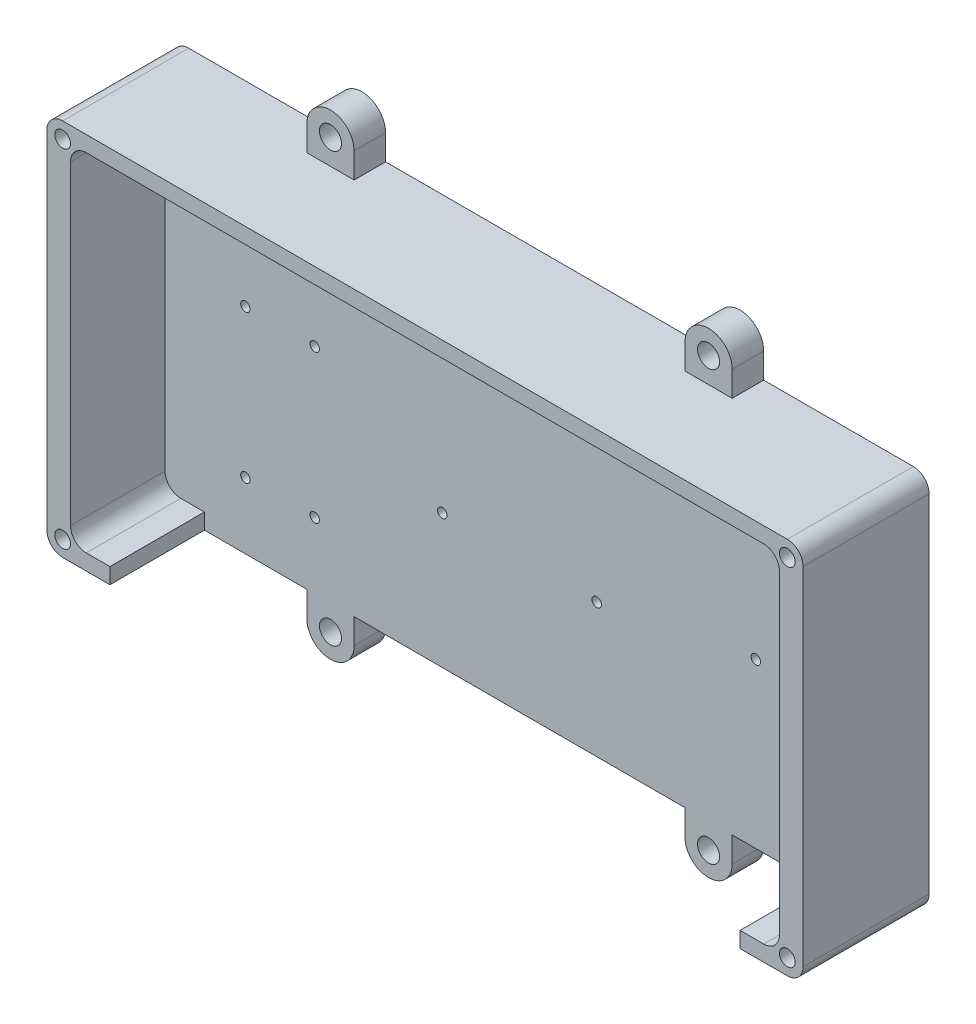
from build123d import *

# Parameters (mm, degrees)
BOSS_EXTRUDE1_DEPTH                 = 10
SKETCH3_R                           = 3.5
IZVRTINA_VIJACENJE_NOSILCA_M7_DEPTH = 10
BOSS_EXTRUDE2_DEPTH                 = 30
SKETCH8_W                           = 200
SKETCH8_H                           = 30
IZVRTINA_KABLI_DEPTH                = 5
SKETCH10_R                          = 1.5
IZVRTINE_RPI_M2_5_HEAT_INSERT_DEPTH = 10
SKETCH11_R                          = 1.5
IZVRTINE_BUCK_M2_HEAT_INSERTS_DEPTH = 10
SKETCH12_R                          = 1.5
IZVRTINE_UNO_M2_5_HEAT_INSERT_DEPTH = 10
SKETCH14_R                          = 2.5
IZVRTINE_TOP_M4_HEAT_INSERT_DEPTH   = 6


with BuildPart() as part:
    # Sketch2 → Boss-Extrude1 (new body)
    with BuildSketch(Plane.XY):
        with BuildLine():
            Line((52.5, 60), (-52.5, 60))
            Line((-52.5, 60), (-52.5, 68))
            ThreePointArc((-52.5, 68), (-60, 75.5), (-67.5, 68))
            Line((-67.5, 68), (-67.5, 60))
            Line((-67.5, 60), (-115, 60))
            ThreePointArc((-115, 60), (-118.535533906, 58.535533906), (-120, 55))
            Line((-120, 55), (-120, -55))
            ThreePointArc((-120, -55), (-118.535533906, -58.535533906), (-115, -60))
            Line((-115, -60), (-67.5, -60))
            Line((-67.5, -60), (-67.5, -68))
            ThreePointArc((-67.5, -68), (-60, -75.5), (-52.5, -68))
            Line((-52.5, -68), (-52.5, -60))
            Line((-52.5, -60), (52.5, -60))
            Line((52.5, -60), (52.5, -68))
            ThreePointArc((52.5, -68), (60, -75.5), (67.5, -68))
            Line((67.5, -68), (67.5, -60))
            Line((67.5, -60), (115, -60))
            ThreePointArc((115, -60), (118.535533906, -58.535533906), (120, -55))
            Line((120, -55), (120, 55))
            ThreePointArc((120, 55), (118.535533906, 58.535533906), (115, 60))
            Line((115, 60), (67.5, 60))
            Line((67.5, 60), (67.5, 68))
            ThreePointArc((67.5, 68), (60, 75.5), (52.5, 68))
            Line((52.5, 68), (52.5, 60))
        make_face()
    extrude(amount=BOSS_EXTRUDE1_DEPTH)

    # Sketch3 → izvrtina_vijacenje_nosilca_m7 (cut)
    with BuildSketch(Plane.XY.offset(10)):
        with Locations((-60, 68)):
            Circle(SKETCH3_R)
        with Locations((-60, -68)):
            Circle(SKETCH3_R)
        with Locations((60, -68)):
            Circle(SKETCH3_R)
        with Locations((60, 68)):
            Circle(SKETCH3_R)
    extrude(amount=-IZVRTINA_VIJACENJE_NOSILCA_M7_DEPTH, mode=Mode.SUBTRACT)

    # Sketch7 → Boss-Extrude2 (add)
    with BuildSketch(Plane.XY.offset(10)):
        with BuildLine():
            Line((-115, -60), (115, -60))
            ThreePointArc((115, -60), (118.535533906, -58.535533906), (120, -55))
            Line((120, -55), (120, 55))
            ThreePointArc((120, 55), (118.535533906, 58.535533906), (115, 60))
            Line((115, 60), (-115, 60))
            ThreePointArc((-115, 60), (-118.535533906, 58.535533906), (-120, 55))
            Line((-120, 55), (-120, -55))
            ThreePointArc((-120, -55), (-118.535533906, -58.535533906), (-115, -60))
        make_face()
        with BuildLine():
            Line((-112.5, 50), (-112.5, -50))
            ThreePointArc((-112.5, -50), (-111.035533906, -53.535533906), (-107.5, -55))
            Line((-107.5, -55), (107.5, -55))
            ThreePointArc((107.5, -55), (111.035533906, -53.535533906), (112.5, -50))
            Line((112.5, -50), (112.5, 50))
            ThreePointArc((112.5, 50), (111.035533906, 53.535533906), (107.5, 55))
            Line((107.5, 55), (-107.5, 55))
            ThreePointArc((-107.5, 55), (-111.035533906, 53.535533906), (-112.5, 50))
        make_face(mode=Mode.SUBTRACT)
    extrude(amount=BOSS_EXTRUDE2_DEPTH)

    # Sketch8 → izvrtina_kabli (cut)
    with BuildSketch(Plane.XZ.offset(60)):
        with Locations((0, 25)):
            Rectangle(SKETCH8_W, SKETCH8_H)
    extrude(amount=-IZVRTINA_KABLI_DEPTH, mode=Mode.SUBTRACT)

    # Sketch10 → izvrtine_rpi_m2.5_heat_insert (cut)
    with BuildSketch(Plane.XY.offset(10)):
        with Locations((24.5, 40.5)):
            Circle(SKETCH10_R)
        with Locations((24.5, -17.5)):
            Circle(SKETCH10_R)
        with Locations((-24.5, -17.5)):
            Circle(SKETCH10_R)
        with Locations((-24.5, 40.5)):
            Circle(SKETCH10_R)
    extrude(amount=-IZVRTINE_RPI_M2_5_HEAT_INSERT_DEPTH, mode=Mode.SUBTRACT)

    # Sketch11 → izvrtine_buck_m2_heat_inserts (cut)
    with BuildSketch(Plane.XY.offset(10)):
        with Locations((-87, 8)):
            Circle(SKETCH11_R)
        with Locations((-65, 8)):
            Circle(SKETCH11_R)
        with Locations((-65, -39)):
            Circle(SKETCH11_R)
        with Locations((-87, -39)):
            Circle(SKETCH11_R)
    extrude(amount=-IZVRTINE_BUCK_M2_HEAT_INSERTS_DEPTH, mode=Mode.SUBTRACT)

    # Sketch12 → izvrtine_uno_m2.5_heat_insert (cut)
    with BuildSketch(Plane.XY.offset(10)):
        with Locations((75, 34)):
            Circle(SKETCH12_R)
        with Locations((75, -8)):
            Circle(SKETCH12_R)
    extrude(amount=-IZVRTINE_UNO_M2_5_HEAT_INSERT_DEPTH, mode=Mode.SUBTRACT)

    # Sketch14 → izvrtine_top_m4_heat_insert (cut)
    with BuildSketch(Plane.XY.offset(40)):
        with Locations((-115, 55)):
            Circle(SKETCH14_R)
        with Locations((115, 55)):
            Circle(SKETCH14_R)
        with Locations((115, -55)):
            Circle(SKETCH14_R)
        with Locations((-115, -55)):
            Circle(SKETCH14_R)
    extrude(amount=-IZVRTINE_TOP_M4_HEAT_INSERT_DEPTH, mode=Mode.SUBTRACT)


solid = part.part
